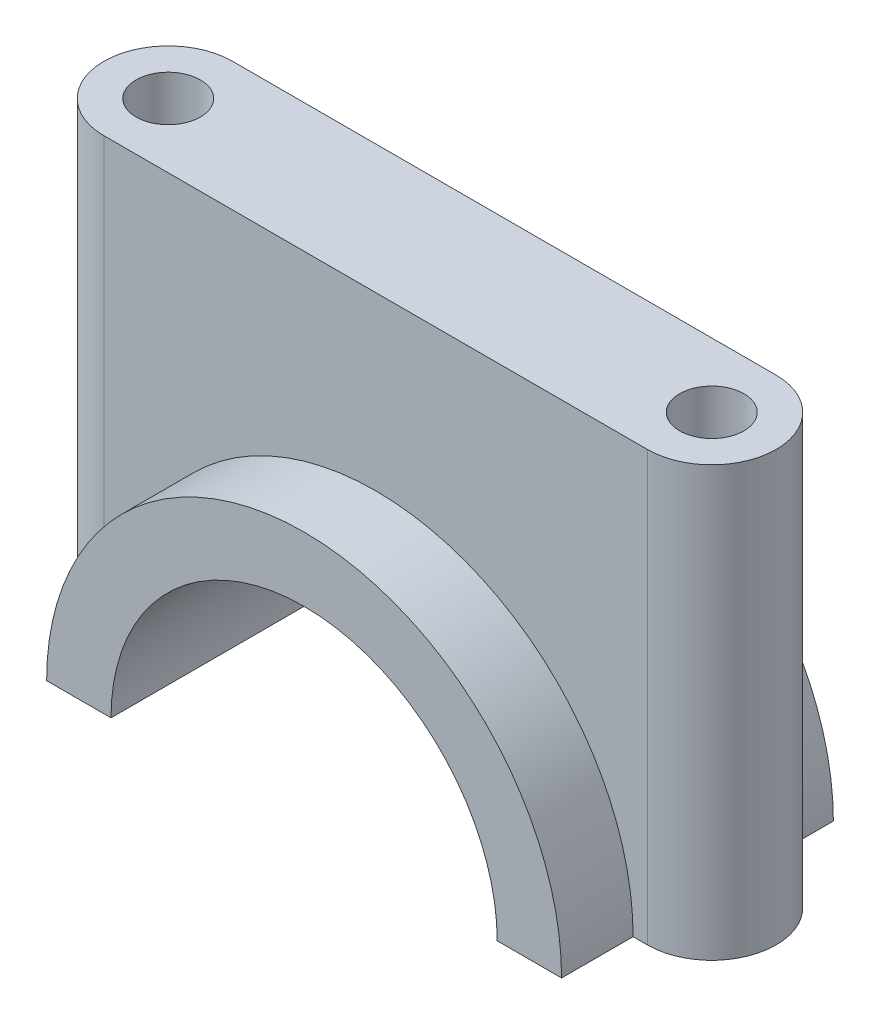
from build123d import *

# Parameters (mm, degrees)
BOSS_EXTRUDE1_DEPTH = 19
BOSS_EXTRUDE2_DEPTH = 60
CUT_EXTRUDE1_DEPTH  = 29
SKETCH4_R           = 4.5
CUT_EXTRUDE2_DEPTH  = 61


with BuildPart() as part:
    # Sketch1 → Boss-Extrude1 (new body, symmetric)
    with BuildSketch(Plane.XY):
        with BuildLine():
            Line((-36, 0), (-27, 0))
            ThreePointArc((-27, 0), (0, 27), (27, 0))
            Line((27, 0), (36, 0))
            ThreePointArc((36, 0), (0, 36), (-36, 0))
        make_face()
    extrude(amount=BOSS_EXTRUDE1_DEPTH, both=True)

    # Sketch2 → Boss-Extrude2 (add)
    with BuildSketch(Plane(origin=(0, 60, 0), x_dir=(-1, 0, 0), z_dir=(0, -1, 0))):
        with BuildLine():
            Line((-38, 9), (38, 9))
            ThreePointArc((38, 9), (47, 0), (38, -9))
            Line((38, -9), (-38, -9))
            ThreePointArc((-38, -9), (-47, 0), (-38, 9))
        make_face()
    extrude(amount=BOSS_EXTRUDE2_DEPTH)

    # Sketch3 → Cut-Extrude1 (cut, through all)
    with BuildSketch(Plane.XY.offset(9)):
        with BuildLine():
            Line((-27, 0), (27, 0))
            ThreePointArc((27, 0), (0, 27), (-27, 0))
        make_face()
    extrude(amount=-CUT_EXTRUDE1_DEPTH, mode=Mode.SUBTRACT)

    # Sketch4 → Cut-Extrude2 (cut, through all)
    with BuildSketch(Plane.XZ):
        with Locations((-38, 0)):
            Circle(SKETCH4_R)
        with Locations((38, 0)):
            Circle(SKETCH4_R)
    extrude(amount=-CUT_EXTRUDE2_DEPTH, mode=Mode.SUBTRACT)


solid = part.part
